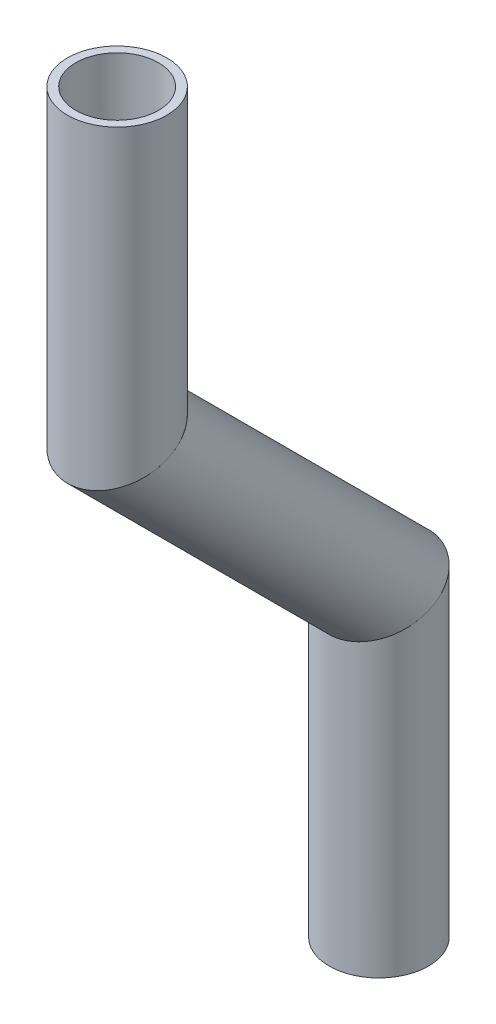
from build123d import *

# Parameters (mm, degrees)
SKETCH11_R                = 6.35
SKETCH11_R_2              = 5.2832
PIPE_0_5_SCH_40_1_DEPTH   = 42.819743879
SKETCH11_ON_SEGMENT_2_R   = 6.35
SKETCH11_ON_SEGMENT_2_R_2 = 5.2832
PIPE_0_5_SCH_40_1_2_DEPTH = 56.730691165
SKETCH11_ON_SEGMENT_3_R   = 6.35
SKETCH11_ON_SEGMENT_3_R_2 = 5.2832
PIPE_0_5_SCH_40_1_3_DEPTH = 44.043224164


with BuildPart() as part:
    # Sketch11 → Pipe 0.5 SCH 40(1) (new body)
    with BuildSketch(Plane(origin=(0, -187.756263613, 303.250213328), x_dir=(0, 0, -1), z_dir=(0, -1, 0))):
        Circle(SKETCH11_R)
        Circle(SKETCH11_R_2, mode=Mode.SUBTRACT)
    extrude(amount=PIPE_0_5_SCH_40_1_DEPTH)

    # Pipe 0.5 SCH 40(1) mitre 1
    split(bisect_by=Plane(origin=(0, -225.856263613, 303.250213328), x_dir=(-1, 0, 0), z_dir=(0, 0.923879533, 0.382683432)), keep=Keep.TOP)


with BuildPart() as body_2:
    # Sketch11 on segment 2 (carried to segment 2) → Pipe 0.5 SCH 40_1 2 (new body)
    with BuildSketch(Plane(origin=(0, -222.518900711, 306.58757623), x_dir=(0, 0.707106781, -0.707106781), z_dir=(0, -0.707106781, -0.707106781))):
        Circle(SKETCH11_ON_SEGMENT_2_R)
        Circle(SKETCH11_ON_SEGMENT_2_R_2, mode=Mode.SUBTRACT)
    extrude(amount=PIPE_0_5_SCH_40_1_2_DEPTH)

    # Pipe 0.5 SCH 40_1 2 mitre 1
    split(bisect_by=Plane(origin=(0, -225.856263613, 303.250213328), x_dir=(1, 0, 0), z_dir=(0, -0.923879533, -0.382683432)), keep=Keep.TOP)

    # Pipe 0.5 SCH 40_1 2 mitre 2
    split(bisect_by=Plane(origin=(0, -259.296194232, 269.810282709), x_dir=(-1, 0, 0), z_dir=(0, 0.923879533, 0.382683432)), keep=Keep.TOP)


with BuildPart() as body_3:
    # Sketch11 on segment 3 (carried to segment 3) → Pipe 0.5 SCH 40_1 3 (new body)
    with BuildSketch(Plane(origin=(0, -254.576450353, 269.810282709), x_dir=(0, 0, -1), z_dir=(0, -1, 0))):
        Circle(SKETCH11_ON_SEGMENT_3_R)
        Circle(SKETCH11_ON_SEGMENT_3_R_2, mode=Mode.SUBTRACT)
    extrude(amount=PIPE_0_5_SCH_40_1_3_DEPTH)

    # Pipe 0.5 SCH 40_1 3 mitre 1
    split(bisect_by=Plane(origin=(0, -259.296194232, 269.810282709), x_dir=(1, 0, 0), z_dir=(0, -0.923879533, -0.382683432)), keep=Keep.TOP)


solid = Compound([part.part, body_2.part, body_3.part])
